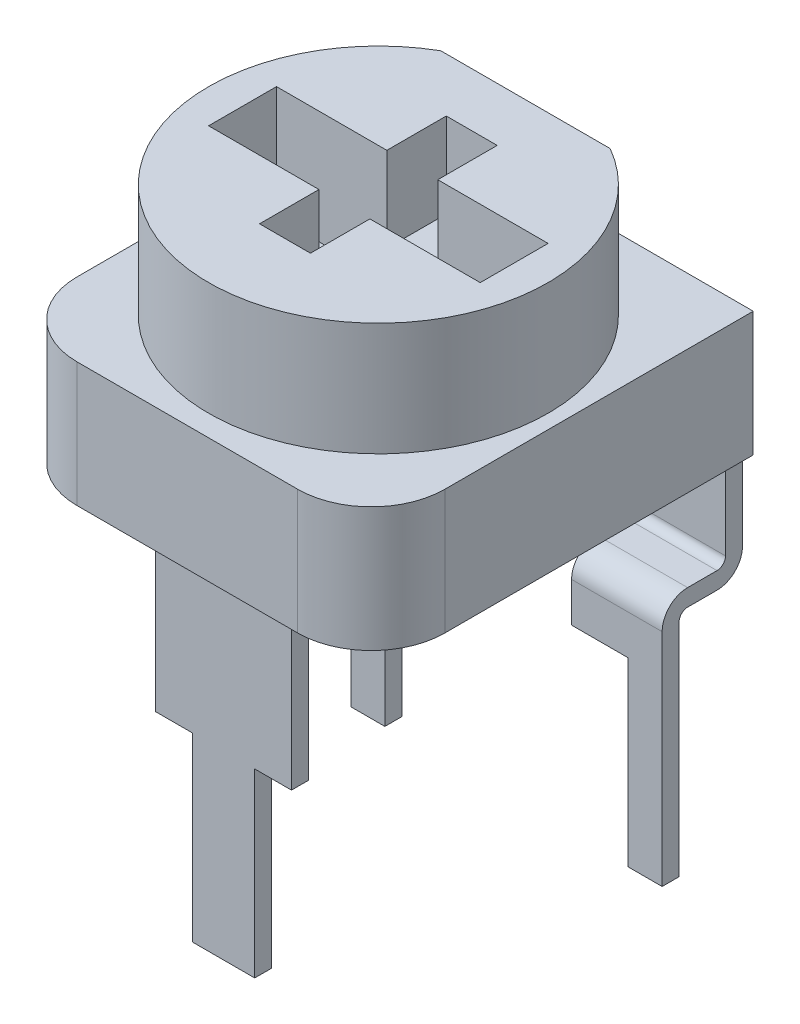
from build123d import *

# Parameters (mm, degrees)
ESQUISSE1_W                = 4.8
ESQUISSE1_H                = 1.2
BOSS_EXTRU_1_DEPTH         = 2
ESQUISSE2_W                = 0.9
ESQUISSE2_H                = 3.3
ENL_V_MAT_EXTRU_1_DEPTH    = 1.5
BOSS_EXTRU_2_DEPTH         = 2.2
EXTRU_MINCE1_START         = -1.95
EXTRU_MINCE1_DEPTH         = 0.8
R_P_TITION_LIN_AIRE1_COUNT = 2
R_P_TITION_LIN_AIRE1_PITCH = 3.9
ESQUISSE5_W                = 0.3
ESQUISSE5_H                = 6.3
EXTRU_MINCE2_DEPTH         = 1.2
ESQUISSE6_W                = 1.6
ESQUISSE6_H                = 3.2
ENL_V_MAT_EXTRU_2_DEPTH    = 6.94


with BuildPart() as part:
    # Esquisse1 → Boss.-Extru.1 (new body)
    with BuildSketch(Plane(origin=(0, 0, 0), x_dir=(1, 0, 0), z_dir=(0, 1, 0))):
        with BuildLine():
            Line((-1.496662955, 2.6), (1.496662955, 2.6))
            ThreePointArc((1.496662955, 2.6), (0, -3), (-1.496662955, 2.6))
        make_face()
        Rectangle(ESQUISSE1_W, ESQUISSE1_H, mode=Mode.SUBTRACT)
    extrude(amount=BOSS_EXTRU_1_DEPTH)

    # Esquisse2 → Enlèv. mat.-Extru.1 (cut)
    with BuildSketch(Plane(origin=(0, 2, 0), x_dir=(-1, 0, 0), z_dir=(0, 1, 0))):
        Rectangle(ESQUISSE2_W, ESQUISSE2_H)
    extrude(amount=-ENL_V_MAT_EXTRU_1_DEPTH, mode=Mode.SUBTRACT)

    # Esquisse3 → Boss.-Extru.2 (add)
    with BuildSketch(Plane(origin=(0, 0, 0), x_dir=(1, 0, 0), z_dir=(0, 1, 0))):
        with BuildLine():
            Line((-1.95, -3.375), (1.95, -3.375))
            ThreePointArc((1.95, -3.375), (2.869238816, -2.994238816), (3.25, -2.075))
            Line((3.25, -2.075), (3.25, 3.375))
            Line((3.25, 3.375), (-3.25, 3.375))
            Line((-3.25, 3.375), (-3.25, -2.075))
            ThreePointArc((-3.25, -2.075), (-2.869238816, -2.994238816), (-1.95, -3.375))
        make_face()
    extrude(amount=-BOSS_EXTRU_2_DEPTH)

    # Esquisse4 → Extru.-Mince1 (add, symmetric)
    with BuildSketch(Plane(origin=(0, 0, 0), x_dir=(0, 0, -1), z_dir=(1, 0, 0)).offset(EXTRU_MINCE1_START)):
        with BuildLine():
            Line((0.543790291, -1.15), (3.235, -1.15))
            ThreePointArc((3.235, -1.15), (3.341066017, -1.193933983), (3.385, -1.3))
            Line((3.385, -1.3), (3.385, -4))
            ThreePointArc((3.385, -4), (3.341066017, -4.106066017), (3.235, -4.15))
            Line((3.235, -4.15), (2.715, -4.15))
            ThreePointArc((2.715, -4.15), (2.396801948, -4.281801948), (2.265, -4.6))
            Line((2.265, -4.6), (2.265, -8.5))
            Line((2.265, -8.5), (2.565, -8.5))
            Line((2.565, -8.5), (2.565, -4.6))
            ThreePointArc((2.565, -4.6), (2.608933983, -4.493933983), (2.715, -4.45))
            Line((2.715, -4.45), (3.235, -4.45))
            ThreePointArc((3.235, -4.45), (3.553198052, -4.318198052), (3.685, -4))
            Line((3.685, -4), (3.685, -1.3))
            ThreePointArc((3.685, -1.3), (3.553198052, -0.981801948), (3.235, -0.85))
            Line((3.235, -0.85), (0.543790291, -0.85))
            Line((0.543790291, -0.85), (0.543790291, -1.15))
        make_face()
    extru_mince1 = extrude(amount=EXTRU_MINCE1_DEPTH, both=True)

    # Répétition linéaire1: Extru.-Mince1 ×2
    with Locations(*[(i * R_P_TITION_LIN_AIRE1_PITCH, 0, 0) for i in range(1, R_P_TITION_LIN_AIRE1_COUNT)]):
        add(extru_mince1)

    # Esquisse5 → Extru.-Mince2 (add, symmetric)
    with BuildSketch(Plane(origin=(0, 0, 0), x_dir=(0, 0, -1), z_dir=(1, 0, 0))):
        with Locations((-2.585, -5.35)):
            Rectangle(ESQUISSE5_W, ESQUISSE5_H)
    extrude(amount=EXTRU_MINCE2_DEPTH, both=True)

    # Esquisse6 → Enlèv. mat.-Extru.2 (cut, through all)
    with BuildSketch(Plane(origin=(0, 0, -2.565), x_dir=(-1, 0, 0), z_dir=(0, 0, -1))):
        with Locations((-1.35, -6.9)):
            Rectangle(ESQUISSE6_W, ESQUISSE6_H)
        with Locations((1.35, -6.9)):
            Rectangle(ESQUISSE6_W, ESQUISSE6_H)
    extrude(amount=-ENL_V_MAT_EXTRU_2_DEPTH, mode=Mode.SUBTRACT)


solid = part.part
